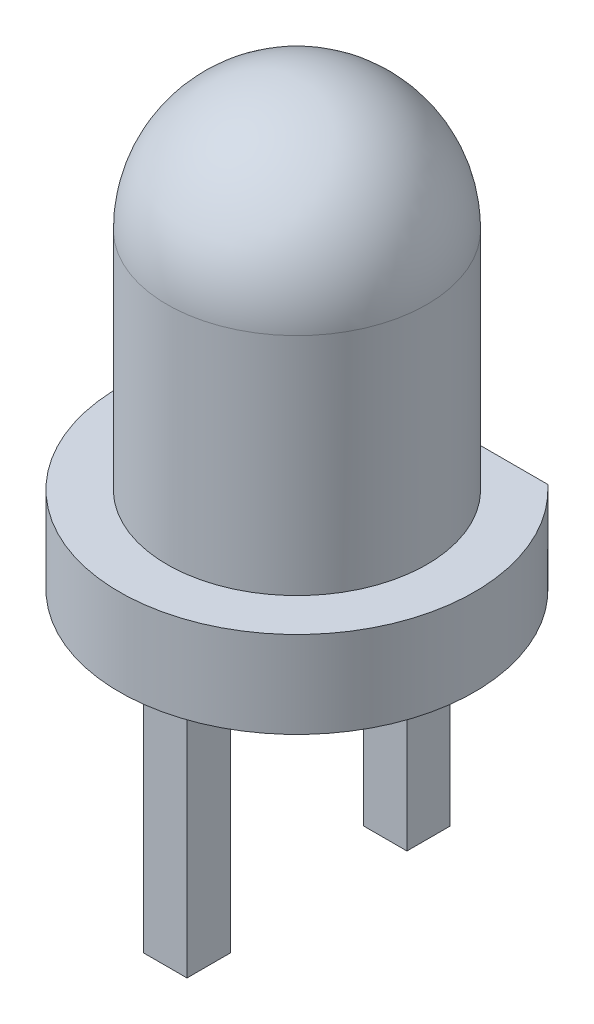
from build123d import *

# Parameters (mm, degrees)
CUT_EXTRUDE1_DEPTH  = 2
SKETCH3_W           = 0.5
SKETCH3_H           = 0.5
BOSS_EXTRUDE1_DEPTH = 3


with BuildPart() as part:
    # Sketch1 → Revolve1 (revolve)
    with BuildSketch(Plane.XY):
        with BuildLine():
            Line((-1.5, 2.6), (-1.5, 0))
            Line((-1.5, 0), (-2.05, 0))
            Line((-2.05, 0), (-2.05, -1))
            Line((-2.05, -1), (0, -1))
            Line((0, -1), (0, 4.1))
            ThreePointArc((0, 4.1), (-1.060660172, 3.660660172), (-1.5, 2.6))
        make_face()
    revolve(axis=Axis((0, 4.1, 0), (0, -1, 0)))

    # Sketch2 → Cut-Extrude1 (cut, through all)
    with BuildSketch(Plane(origin=(0, 0, 0), x_dir=(1, 0, 0), z_dir=(0, 1, 0))):
        Polygon((-1.949403326, 1.5), (2.097394678, 1.5), (0.505211857, 3.403801095), align=None)
    extrude(amount=-CUT_EXTRUDE1_DEPTH, mode=Mode.SUBTRACT)

    # Sketch3 → Boss-Extrude1 (add)
    with BuildSketch(Plane.XZ.offset(1)):
        with Locations((0, 1.27)):
            Rectangle(SKETCH3_W, SKETCH3_H)
        with Locations((0, -1.27)):
            Rectangle(SKETCH3_W, SKETCH3_H)
    extrude(amount=BOSS_EXTRUDE1_DEPTH)


solid = part.part
